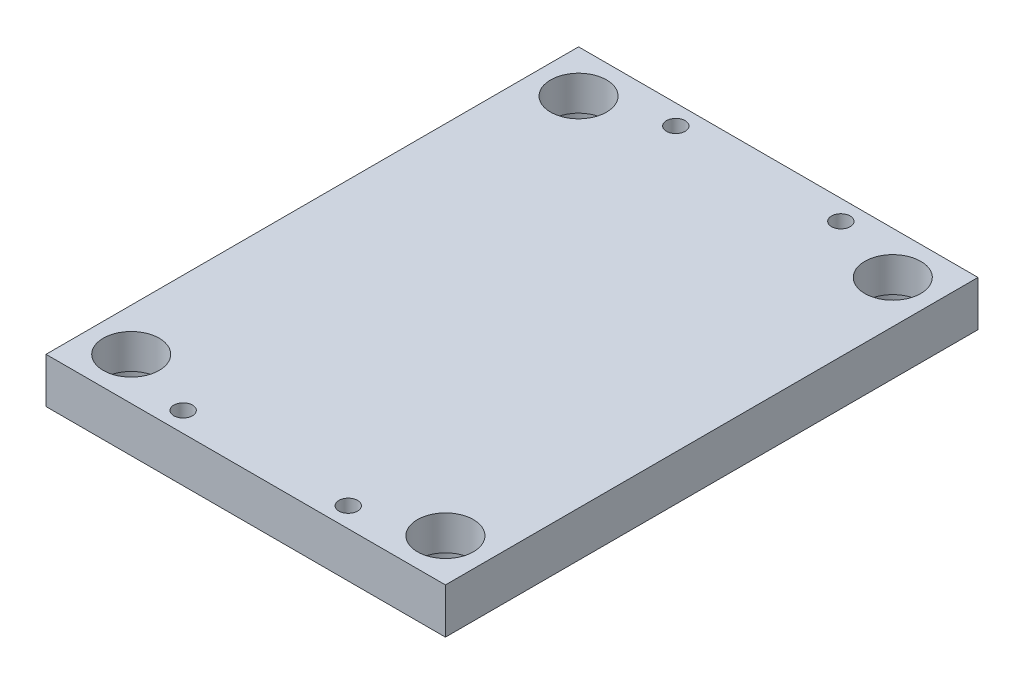
from build123d import *

# Parameters (mm, degrees)
ESBO_O1_W                  = 300
ESBO_O1_H                  = 400
EXTRUS_O1_DEPTH            = 34
FURO_ROSCADO_DE_M161_D     = 14
FURO_ROSCADO_DE_M161_DEPTH = 28
FURO_ROSCADO_DE_M161_TIP   = 4.206024333
FURO1_D                    = 42
FURO1_CBORE_D              = 48
FURO1_CBORE_DEPTH          = 8
FURO2_D                    = 14
FURO2_DEPTH                = 100


with BuildPart() as part:
    # Esboço1 → Extrusão1 (new body)
    with BuildSketch(Plane(origin=(0, 0, 0), x_dir=(1, 0, 0), z_dir=(0, 1, 0))):
        Rectangle(ESBO_O1_W, ESBO_O1_H)
    extrude(amount=EXTRUS_O1_DEPTH)

    # Furo roscado de M161
    with Locations(Plane.XZ):
        with Locations((-118, 119), (118, 119), (-118, -119), (118, -119)):
            Hole(FURO_ROSCADO_DE_M161_D / 2, depth=FURO_ROSCADO_DE_M161_DEPTH)
            with Locations((0, 0, -(FURO_ROSCADO_DE_M161_DEPTH + FURO_ROSCADO_DE_M161_TIP / 2))):  # 118° drill point
                Cone(0, FURO_ROSCADO_DE_M161_D / 2, FURO_ROSCADO_DE_M161_TIP, mode=Mode.SUBTRACT)

    # Furo1 (through all)
    with Locations(Plane.XZ):
        with Locations((118, 168), (118, -168), (-118, -168), (-118, 168)):
            CounterBoreHole(FURO1_D / 2, FURO1_CBORE_D / 2, FURO1_CBORE_DEPTH)

    # Furo2
    with Locations(Plane.XZ):
        with Locations((-62, 185), (-62, -185), (62, 185), (62, -185)):
            Hole(FURO2_D / 2, depth=FURO2_DEPTH)


solid = part.part
